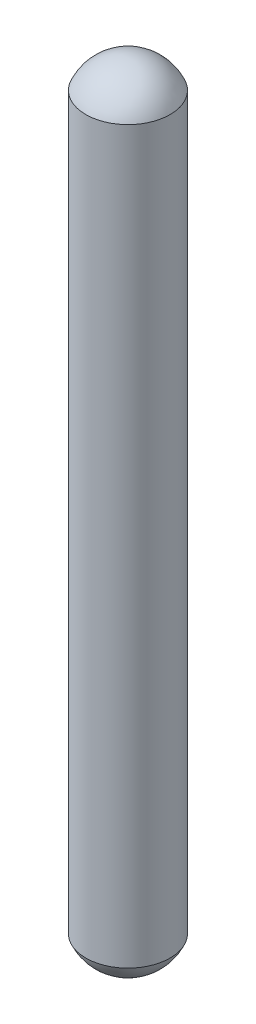
from build123d import *

# Parameters (mm, degrees)
SKETCH1_R           = 3
BOSS_EXTRUDE1_DEPTH = 52
DOME1_FACE_RADIUS   = 3
DOME1_HEIGHT        = 2
DOME2_FACE_RADIUS   = 3
DOME2_HEIGHT        = 2


with BuildPart() as part:
    # Sketch1 → Boss-Extrude1 (new body)
    with BuildSketch(Plane(origin=(0, 0, 0), x_dir=(1, 0, 0), z_dir=(0, 1, 0))):
        Circle(SKETCH1_R)
    extrude(amount=BOSS_EXTRUDE1_DEPTH)

    # Dome1: a dome of height H over a round flat face of radius A is a cap of a sphere of radius (A * A + H * H) / (2 * H)
    dome1_r = (DOME1_FACE_RADIUS * DOME1_FACE_RADIUS + DOME1_HEIGHT * DOME1_HEIGHT) / (2 * DOME1_HEIGHT)
    dome1_base = Plane((0, 52, 0), z_dir=(0, 1, 0))
    with Locations(dome1_base.offset(DOME1_HEIGHT - dome1_r)):
        dome1_ball = Sphere(dome1_r, mode=Mode.PRIVATE)
    add(split(dome1_ball, bisect_by=dome1_base, keep=Keep.TOP, mode=Mode.PRIVATE))

    # Dome2: a dome of height H over a round flat face of radius A is a cap of a sphere of radius (A * A + H * H) / (2 * H)
    dome2_r = (DOME2_FACE_RADIUS * DOME2_FACE_RADIUS + DOME2_HEIGHT * DOME2_HEIGHT) / (2 * DOME2_HEIGHT)
    dome2_base = Plane((0, 0, 0), z_dir=(0, -1, 0))
    with Locations(dome2_base.offset(DOME2_HEIGHT - dome2_r)):
        dome2_ball = Sphere(dome2_r, mode=Mode.PRIVATE)
    add(split(dome2_ball, bisect_by=dome2_base, keep=Keep.TOP, mode=Mode.PRIVATE))


solid = part.part
